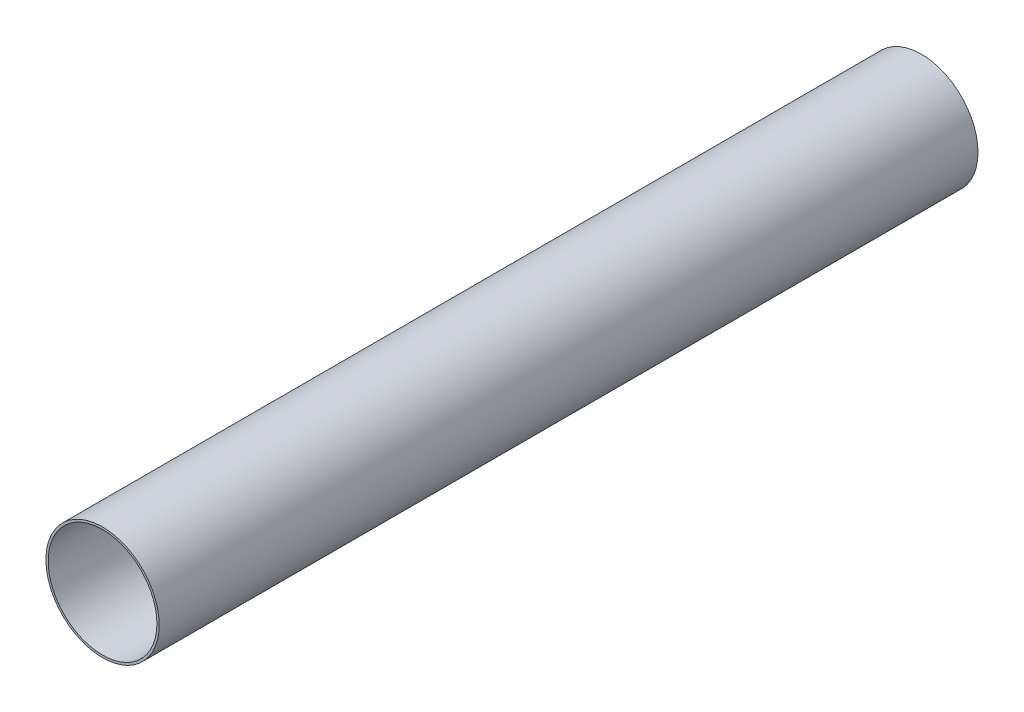
from build123d import *

# Parameters (mm, degrees)
SKETCH1_R           = 55.2
SKETCH1_R_2         = 53
BOSS_EXTRUDE1_DEPTH = 798


with BuildPart() as part:
    # Sketch1 → Boss-Extrude1 (new body)
    with BuildSketch(Plane.XY):
        Circle(SKETCH1_R)
        Circle(SKETCH1_R_2, mode=Mode.SUBTRACT)
    extrude(amount=BOSS_EXTRUDE1_DEPTH)


solid = part.part
